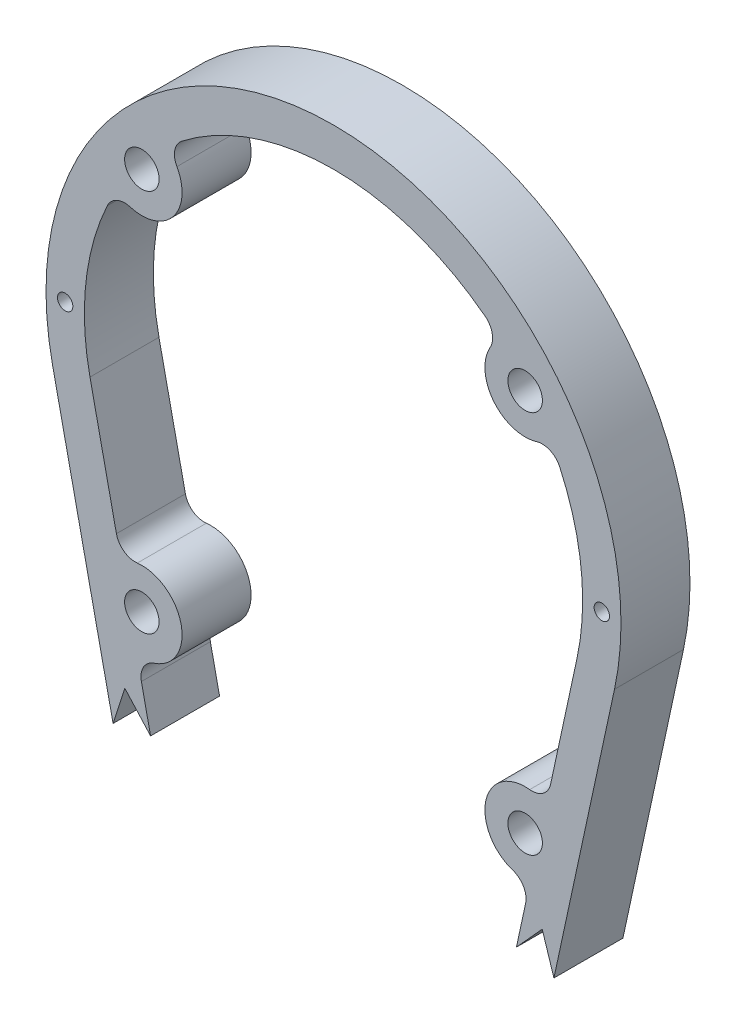
from build123d import *

# Parameters (mm, degrees)
SKETCH3_R           = 4.5
BOSS_EXTRUDE1_DEPTH = 18
FILLET1_R           = 5
FILLET2_R           = 5
CUT_EXTRUDE2_DEPTH  = 19.0000001
SKETCH6_R           = 2
CUT_EXTRUDE3_DEPTH  = 19.0000001


with BuildPart() as part:
    # Sketch3 → Boss-Extrude1 (new body)
    with BuildSketch(Plane.XY):
        with BuildLine():
            Line((-31.929873349, -122.5), (31.929873349, -122.5))
            ThreePointArc((31.929873349, -122.5), (38.210043039, -120.281996444), (41.704324989, -114.611893732))
            Line((41.704324989, -114.611893732), (73.308387301, 31.660797012))
            ThreePointArc((73.308387301, 31.660797012), (0, 122.5), (-73.308387301, 31.660797012))
            Line((-73.308387301, 31.660797012), (-41.704324989, -114.611893732))
            ThreePointArc((-41.704324989, -114.611893732), (-38.210043039, -120.281996444), (-31.929873349, -122.5))
        make_face()
        with Locations((50, -12.5)):
            Circle(SKETCH3_R, mode=Mode.SUBTRACT)
        with Locations((50, 87.5)):
            Circle(SKETCH3_R, mode=Mode.SUBTRACT)
        with Locations((-50, 87.5)):
            Circle(SKETCH3_R, mode=Mode.SUBTRACT)
        with Locations((-50, -12.5)):
            Circle(SKETCH3_R, mode=Mode.SUBTRACT)
        with BuildLine():
            Line((-31.929873349, -112.5), (-51.284518999, -22.921132901))
            ThreePointArc((-51.284518999, -22.921132901), (-39.736825778, -10.282511582), (-55.472323677, -3.538768301))
            Line((-55.472323677, -3.538768301), (-63.533935661, 33.772690744))
            ThreePointArc((-63.533935661, 33.772690744), (-64.271528905, 57.204152316), (-56.648842383, 79.373322021))
            ThreePointArc((-56.648842383, 79.373322021), (-41.800877501, 80.940702001), (-43.531035666, 95.770580418))
            ThreePointArc((-43.531035666, 95.770580418), (0, 112.5), (43.531035666, 95.770580418))
            ThreePointArc((43.531035666, 95.770580418), (41.800877501, 80.940702001), (56.648842383, 79.373322021))
            ThreePointArc((56.648842383, 79.373322021), (64.271528905, 57.204152316), (63.533935661, 33.772690744))
            Line((63.533935661, 33.772690744), (55.472323677, -3.538768301))
            ThreePointArc((55.472323677, -3.538768301), (39.736825778, -10.282511582), (51.284518999, -22.921132901))
            Line((51.284518999, -22.921132901), (31.929873349, -112.5))
            Line((31.929873349, -112.5), (-31.929873349, -112.5))
        make_face(mode=Mode.SUBTRACT)
    extrude(amount=BOSS_EXTRUDE1_DEPTH)

    # Fillet1
    fillet1_edges = [part.edges().sort_by_distance(p)[0] for p in [
        (-31.929873349, -112.5, 9),
        (31.929873349, -112.5, 9),
    ]]
    fillet(fillet1_edges, radius=FILLET1_R)

    # Fillet2
    fillet2_edges = [part.edges().sort_by_distance(p)[0] for p in [
        (51.284518999, -22.921132901, 9),
        (55.472323677, -3.538768301, 9),
        (56.648842383, 79.373322021, 9),
        (43.531035666, 95.770580418, 9),
        (-43.531035666, 95.770580418, 9),
        (-56.648842383, 79.373322021, 9),
        (-55.472323677, -3.538768301, 9),
        (-51.284518999, -22.921132901, 9),
    ]]
    fillet(fillet2_edges, radius=FILLET2_R)

    # Sketch5 → Cut-Extrude2 (cut, through all)
    with BuildSketch(Plane.XY.offset(18)):
        Polygon((47.724403212, -39.39837277), (54.444339069, -31.972010438), (57.506356145, -41.47554836), (70.328868077, -126.043088926), (-63.485047771, -126.043088926), (-57.506356145, -41.47554836), (-54.443982463, -31.973660914), (-47.723687693, -39.401684395), align=None)
    extrude(amount=-CUT_EXTRUDE2_DEPTH, mode=Mode.SUBTRACT)

    # Sketch6 → Cut-Extrude3 (cut, through all)
    with BuildSketch(Plane.XY.offset(18)):
        with Locations((-70, 47.5)):
            Circle(SKETCH6_R)
        with Locations((70, 47.5)):
            Circle(SKETCH6_R)
    extrude(amount=-CUT_EXTRUDE3_DEPTH, mode=Mode.SUBTRACT)


solid = part.part
